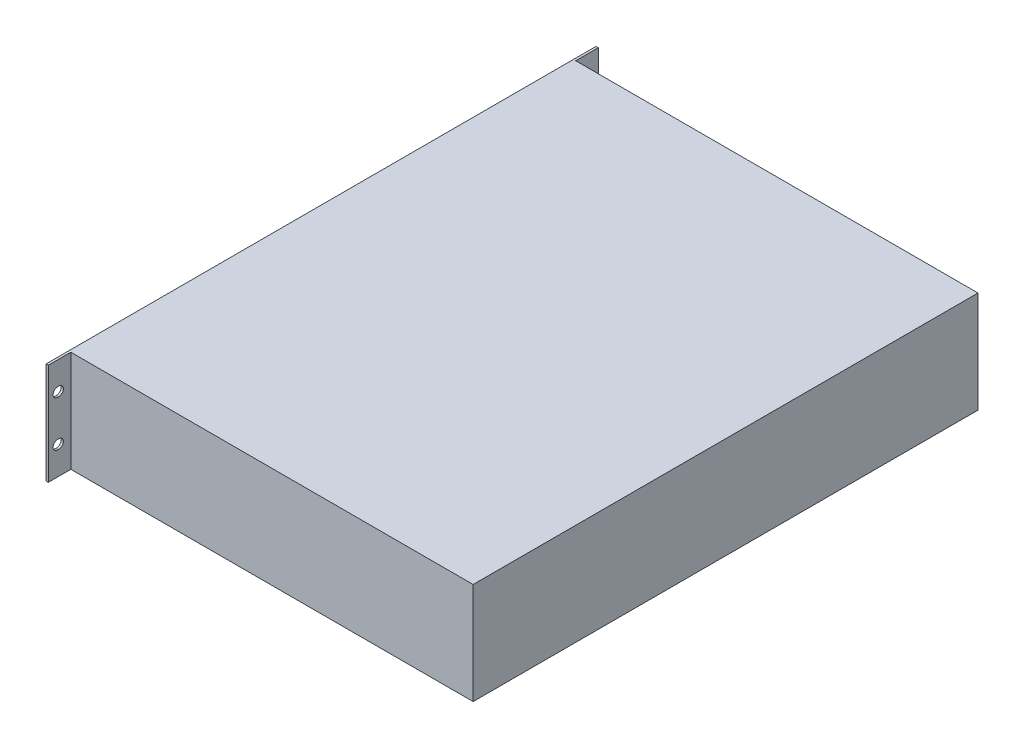
from build123d import *

# Parameters (mm, degrees)
CROQUIS1_W              = 355
CROQUIS1_H              = 443
SALIENTE_EXTRUIR1_DEPTH = 89
CROQUIS2_W              = 482.6
CROQUIS2_H              = 89
SALIENTE_EXTRUIR2_DEPTH = 2


with BuildPart() as part:
    # Croquis1 → Saliente-Extruir1 (new body)
    with BuildSketch(Plane(origin=(0, 0, 0), x_dir=(1, 0, 0), z_dir=(0, 1, 0))):
        Rectangle(CROQUIS1_W, CROQUIS1_H)
    extrude(amount=SALIENTE_EXTRUIR1_DEPTH)

    # Croquis2 → Saliente-Extruir2 (add)
    with BuildSketch(Plane.ZY.offset(177.5)):
        with Locations((0, 44.5)):
            Rectangle(CROQUIS2_W, CROQUIS2_H)
        with BuildLine():
            Line((-233.06, 68.5), (-232.06, 68.5))
            ThreePointArc((-232.06, 68.5), (-228.06, 64.5), (-232.06, 60.5))
            Line((-232.06, 60.5), (-233.06, 60.5))
            ThreePointArc((-233.06, 60.5), (-237.06, 64.5), (-233.06, 68.5))
        make_face(mode=Mode.SUBTRACT)
        with BuildLine():
            Line((-233.06, 20.5), (-232.06, 20.5))
            ThreePointArc((-232.06, 20.5), (-228.06, 24.5), (-232.06, 28.5))
            Line((-232.06, 28.5), (-233.06, 28.5))
            ThreePointArc((-233.06, 28.5), (-237.06, 24.5), (-233.06, 20.5))
        make_face(mode=Mode.SUBTRACT)
        with BuildLine():
            Line((233.06, 68.5), (232.06, 68.5))
            ThreePointArc((232.06, 68.5), (228.06, 64.5), (232.06, 60.5))
            Line((232.06, 60.5), (233.06, 60.5))
            ThreePointArc((233.06, 60.5), (237.06, 64.5), (233.06, 68.5))
        make_face(mode=Mode.SUBTRACT)
        with BuildLine():
            Line((233.06, 20.5), (232.06, 20.5))
            ThreePointArc((232.06, 20.5), (228.06, 24.5), (232.06, 28.5))
            Line((232.06, 28.5), (233.06, 28.5))
            ThreePointArc((233.06, 28.5), (237.06, 24.5), (233.06, 20.5))
        make_face(mode=Mode.SUBTRACT)
    extrude(amount=-SALIENTE_EXTRUIR2_DEPTH)


solid = part.part
